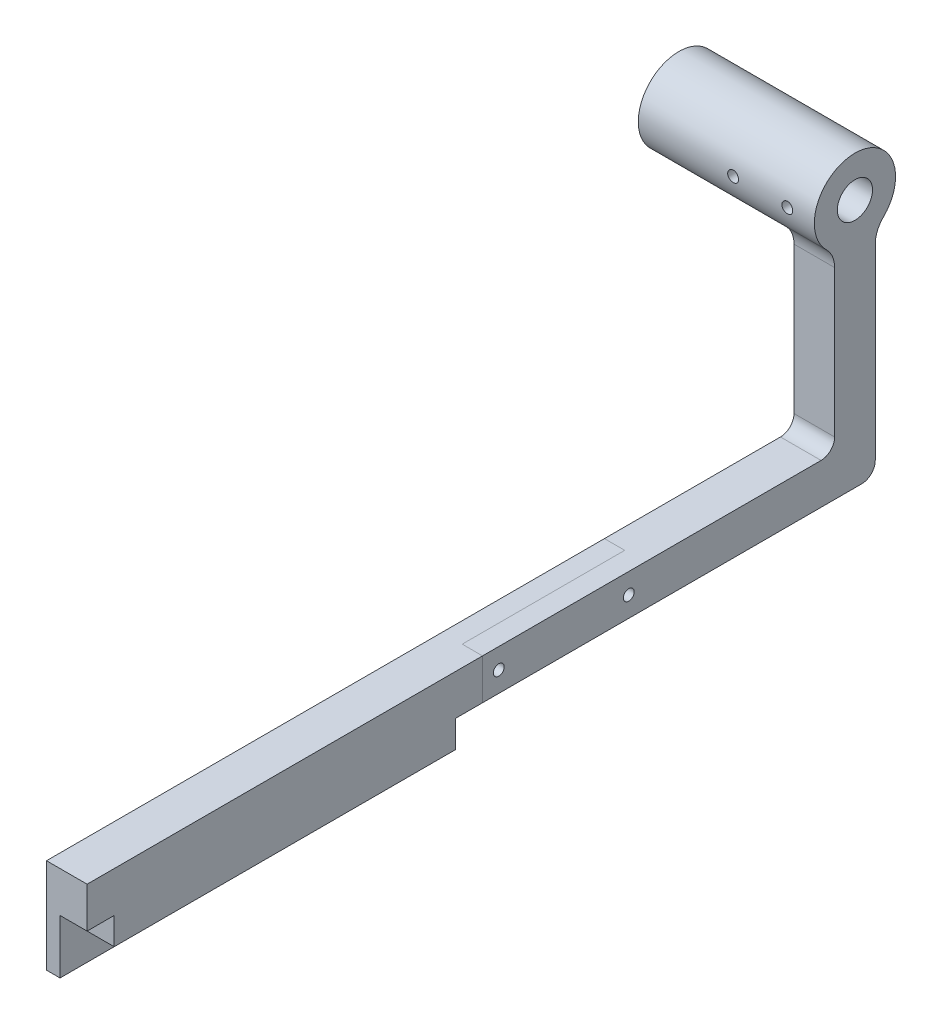
from build123d import *

# Parameters (mm, degrees)
BOSS_EXTRUDE3_DEPTH    = 10
SKETCH8_W              = 146
SKETCH8_H              = 15
BOSS_EXTRUDE6_DEPTH    = 5
SKETCH9_W              = 5
SKETCH9_H              = 146
BOSS_EXTRUDE7_DEPTH    = 20
SKETCH10_R             = 2
CUT_EXTRUDE2_DEPTH     = 20
SKETCH5_R              = 6.5
BOSS_EXTRUDE4_DEPTH    = 15
SKETCH6_R              = 15
SKETCH6_R_2            = 6.5
BOSS_EXTRUDE5_DEPTH    = 50
SKETCH7_R              = 2
CUT_EXTRUDE1_DEPTH     = 50
SKETCH13_R             = 2
CUT_EXTRUDE3_DEPTH     = 20
SPLIT2_SURFACE_1_BACK  = 331.849
SPLIT2_SURFACE_1_DEPTH = 663.698
SPLIT2_SURFACE_2_BACK  = 331.849
SPLIT2_SURFACE_2_DEPTH = 663.698


with BuildPart() as part:
    # Sketch4 → Boss-Extrude3 (new body)
    with BuildSketch(Plane(origin=(0, 0, 0), x_dir=(0, 0, -1), z_dir=(1, 0, 0))):
        Polygon((0, 10), (-10, 10), (-10, 25), (136, 25), (136, 10), (126, 10), (126, 0), (0, 0), align=None)
    extrude(amount=BOSS_EXTRUDE3_DEPTH)

    # Sketch8 → Boss-Extrude6 (add)
    with BuildSketch(Plane.ZY):
        with Locations((-63, 17.5)):
            Rectangle(SKETCH8_W, SKETCH8_H)
    extrude(amount=BOSS_EXTRUDE6_DEPTH)

    # Sketch9 → Boss-Extrude7 (add)
    with BuildSketch(Plane.XZ.offset(-10)):
        with Locations((-2.5, -63)):
            Rectangle(SKETCH9_W, SKETCH9_H)
    extrude(amount=BOSS_EXTRUDE7_DEPTH)

    # Sketch10 → Cut-Extrude2 (cut)
    with BuildSketch(Plane(origin=(0, 0, 0), x_dir=(0, 0, -1), z_dir=(1, 0, 0))):
        with Locations((15, -5)):
            Circle(SKETCH10_R)
        with Locations(Location((111, -5, 0), (0, 0, 180))):
            Circle(SKETCH10_R)
    extrude(amount=-CUT_EXTRUDE2_DEPTH, mode=Mode.SUBTRACT)

    # Sketch5 → Boss-Extrude4 (add)
    with BuildSketch(Plane(origin=(10, 0, 0), x_dir=(0, 0, -1), z_dir=(1, 0, 0))):
        with BuildLine():
            Line((136, 10), (266, 10))
            Line((266, 10), (276, 10))
            ThreePointArc((276, 10), (279.535533906, 11.464466094), (281, 15))
            Line((281, 15), (281, 84.166428929))
            ThreePointArc((281, 84.166428929), (281.780455543, 88.039412275), (284, 91.307857357))
            ThreePointArc((284, 91.307857357), (273.5, 117.02), (263, 91.307857357))
            ThreePointArc((263, 91.307857357), (265.219544457, 88.039412275), (266, 84.166428929))
            Line((266, 84.166428929), (266, 30))
            ThreePointArc((266, 30), (264.535533906, 26.464466094), (261, 25))
            Line((261, 25), (136, 25))
            Line((136, 25), (136, 10))
        make_face()
        with Locations((273.5, 102.02)):
            Circle(SKETCH5_R, mode=Mode.SUBTRACT)
    extrude(amount=-BOSS_EXTRUDE4_DEPTH)

    # Sketch6 → Boss-Extrude5 (add)
    with BuildSketch(Plane.ZY.offset(5)):
        with Locations(Location((-273.5, 102.02, 0), (0, 0, 225.572995999))):
            Circle(SKETCH6_R)
        with Locations(Location((-273.5, 102.02, 0), (0, 0, 180))):
            Circle(SKETCH6_R_2, mode=Mode.SUBTRACT)
    extrude(amount=BOSS_EXTRUDE5_DEPTH)

    # Sketch7 → Cut-Extrude1 (cut)
    with BuildSketch(Plane(origin=(0, 0, -288.5), x_dir=(-1, 0, 0), z_dir=(0, 0, -1))):
        with Locations((20, 102.02)):
            Circle(SKETCH7_R)
        with Locations((0, 102.02)):
            Circle(SKETCH7_R)
    extrude(amount=-CUT_EXTRUDE1_DEPTH, mode=Mode.SUBTRACT)

    # Sketch13 → Cut-Extrude3 (cut)
    with BuildSketch(Plane.ZY.offset(5)):
        with Locations((-190, 17.5)):
            Circle(SKETCH13_R)
        with Locations((-142, 17.5)):
            Circle(SKETCH13_R)
    extrude(amount=-CUT_EXTRUDE3_DEPTH, mode=Mode.SUBTRACT)


with BuildPart() as body_2:
    # Split2: the piece behind the surface
    add(part.part)
    # Split2 surface: a surface, the sketch's curves swept straight by 663.698 mm
    with BuildLine(Plane(origin=(0, 25, 0), x_dir=(1, 0, 0), z_dir=(0, 1, 0)).offset(-SPLIT2_SURFACE_1_BACK), mode=Mode.PRIVATE) as split2_surface_1_path:
        Line((-5, 196), (2.5, 196))
        Line((2.5, 196), (2.5, 136))
        Line((2.5, 136), (10, 136))
    split2_surface_1 = Shell.extrude(split2_surface_1_path.wire(), (0 * SPLIT2_SURFACE_1_DEPTH, 1 * SPLIT2_SURFACE_1_DEPTH, 0 * SPLIT2_SURFACE_1_DEPTH))
    split(bisect_by=split2_surface_1, keep=Keep.BOTTOM)


with BuildPart() as part_1:
    add(part.part)

    # Split2: split by a surface, the side it looks to stays
    # Split2 surface: a surface, the sketch's curves swept straight by 663.698 mm
    with BuildLine(Plane(origin=(0, 25, 0), x_dir=(1, 0, 0), z_dir=(0, 1, 0)).offset(-SPLIT2_SURFACE_2_BACK), mode=Mode.PRIVATE) as split2_surface_2_path:
        Line((-5, 196), (2.5, 196))
        Line((2.5, 196), (2.5, 136))
        Line((2.5, 136), (10, 136))
    split2_surface_2 = Shell.extrude(split2_surface_2_path.wire(), (0 * SPLIT2_SURFACE_2_DEPTH, 1 * SPLIT2_SURFACE_2_DEPTH, 0 * SPLIT2_SURFACE_2_DEPTH))
    split(bisect_by=split2_surface_2, keep=Keep.TOP)


solid = Compound([body_2.part, part_1.part])
